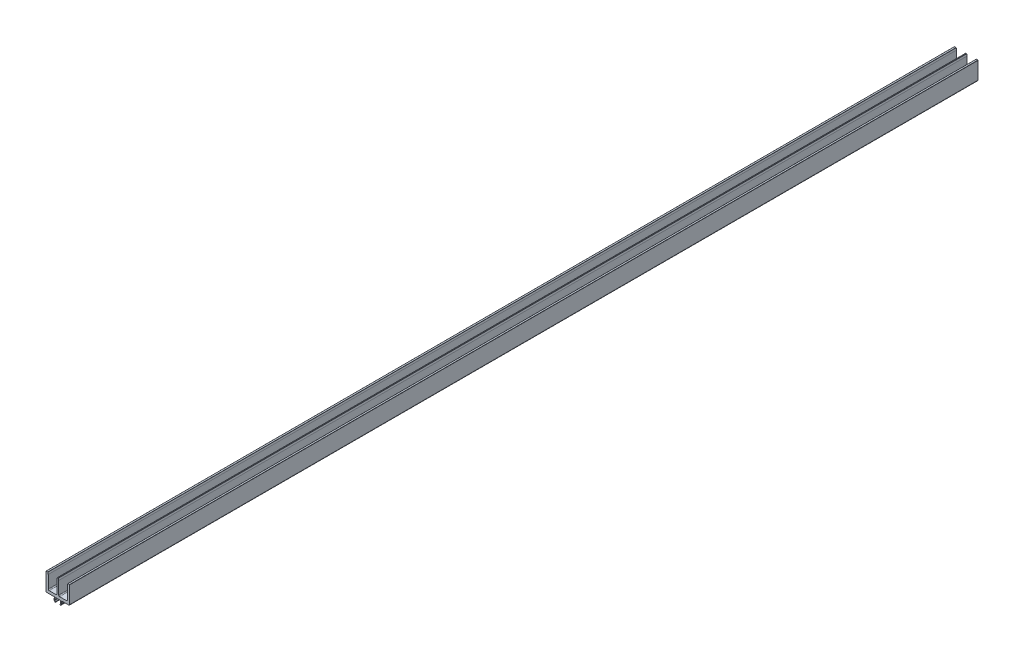
from build123d import *

# Parameters (mm, degrees)
EXTRUDE_1_DEPTH = 500


with BuildPart() as part:
    # 草图9 → 拉伸1 (new body, symmetric)
    with BuildSketch(Plane.XY):
        with BuildLine():
            Line((-1, 18), (-0.997378521, 4))
            ThreePointArc((-0.997378521, 4), (-1.29027174, 3.292893219), (-1.997378521, 3))
            Line((-1.997378521, 3), (-9.5, 3))
            ThreePointArc((-9.5, 3), (-10.207106781, 3.292893219), (-10.5, 4))
            Line((-10.5, 4), (-10.5, 18))
            Line((-10.5, 18), (-10.962126781, 19.848507125))
            ThreePointArc((-10.962126781, 19.848507125), (-11.033072839, 19.957641088), (-11.156155281, 20))
            Line((-11.156155281, 20), (-12.8, 20))
            ThreePointArc((-12.8, 20), (-12.941421356, 19.941421356), (-13, 19.8))
            Line((-13, 19.8), (-13, 1))
            ThreePointArc((-13, 1), (-12.707106781, 0.292893219), (-12, 0))
            Line((-12, 0), (-3.712080642, 0))
            Line((-3.712080642, 0), (-4.1, -2.2))
            Line((-4.1, -2.2), (-4.395740138, -2.712236945))
            Line((-4.395740138, -2.712236945), (-3.363574657, -4.5))
            ThreePointArc((-3.363574657, -4.5), (-2.680561955, -4.683012702), (-2.497549254, -4))
            Line((-2.497549254, -4), (-3.190369577, -2.8))
            Line((-3.190369577, -2.8), (-2.769508091, -0.413175911))
            ThreePointArc((-2.769508091, -0.413175911), (-2.59849802, -0.116977778), (-2.277104215, 0))
            Line((-2.277104215, 0), (2.277104215, 0))
            ThreePointArc((2.277104215, 0), (2.59849802, -0.116977778), (2.769508091, -0.413175911))
            Line((2.769508091, -0.413175911), (3.190369577, -2.8))
            Line((3.190369577, -2.8), (2.497549254, -4))
            ThreePointArc((2.497549254, -4), (2.680561955, -4.683012702), (3.363574657, -4.5))
            Line((3.363574657, -4.5), (4.395740138, -2.712236945))
            Line((4.395740138, -2.712236945), (4.1, -2.2))
            Line((4.1, -2.2), (3.712080642, 0))
            Line((3.712080642, 0), (12, 0))
            ThreePointArc((12, 0), (12.707106781, 0.292893219), (13, 1))
            Line((13, 1), (13, 19.8))
            ThreePointArc((13, 19.8), (12.941421356, 19.941421356), (12.8, 20))
            Line((12.8, 20), (11.158776943, 20))
            ThreePointArc((11.158776943, 20), (11.035799699, 19.957723167), (10.964813339, 19.848765973))
            Line((10.964813339, 19.848765973), (10.5, 18))
            Line((10.5, 18), (10.5, 4))
            ThreePointArc((10.5, 4), (10.207106781, 3.292893219), (9.5, 3))
            Line((9.5, 3), (2, 3))
            ThreePointArc((2, 3), (1.292893219, 3.292893219), (1, 4))
            Line((1, 4), (1, 18))
            Line((1, 18), (0.537873219, 19.848507125))
            ThreePointArc((0.537873219, 19.848507125), (0.466927161, 19.957641088), (0.343844719, 20))
            Line((0.343844719, 20), (-0.34122324, 20))
            ThreePointArc((-0.34122324, 20), (-0.464305682, 19.957641088), (-0.53525174, 19.848507125))
            Line((-0.53525174, 19.848507125), (-1, 18))
        make_face()
    extrude(amount=EXTRUDE_1_DEPTH, both=True)


solid = part.part
